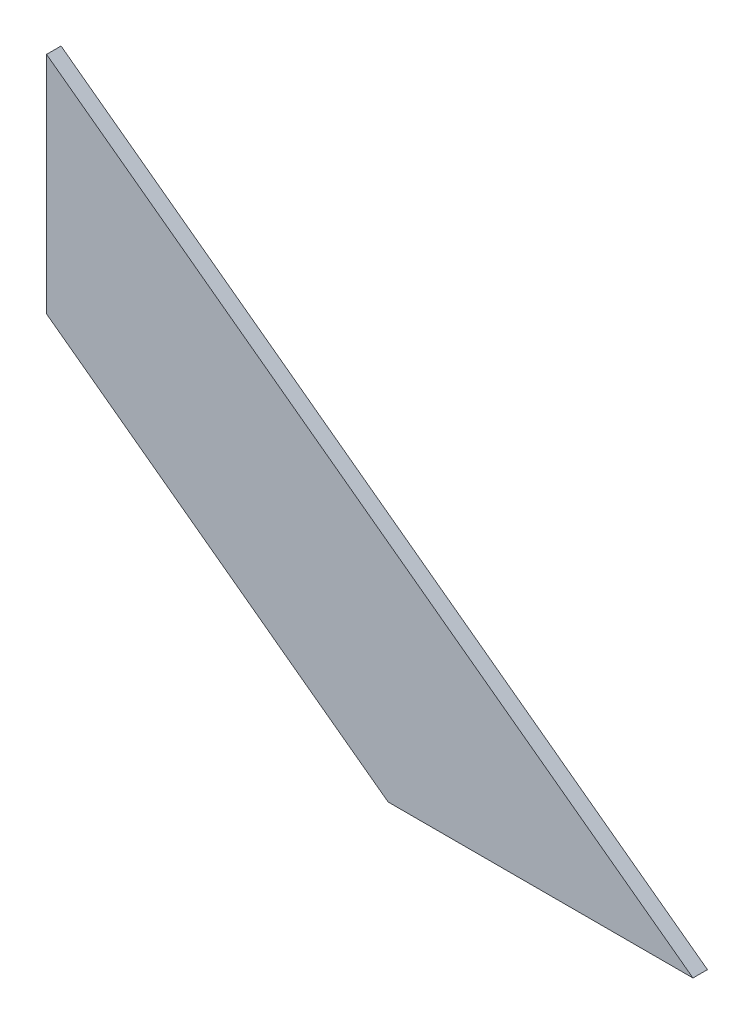
from build123d import *

# Parameters (mm, degrees)
BOSS_EXTRUDE1_DEPTH = 1.524


with BuildPart() as part:
    # Sketch4 → Boss-Extrude1 (new body)
    with BuildSketch(Plane(origin=(0, 0, 0), x_dir=(-1, 0, 0), z_dir=(0, 0, -1))):
        Polygon((471.292522592, -20.034828887), (539.362495023, 30.162192579), (539.362495023, 6.492562277), (503.389866918, -20.034828887), align=None)
    extrude(amount=BOSS_EXTRUDE1_DEPTH)


solid = part.part
